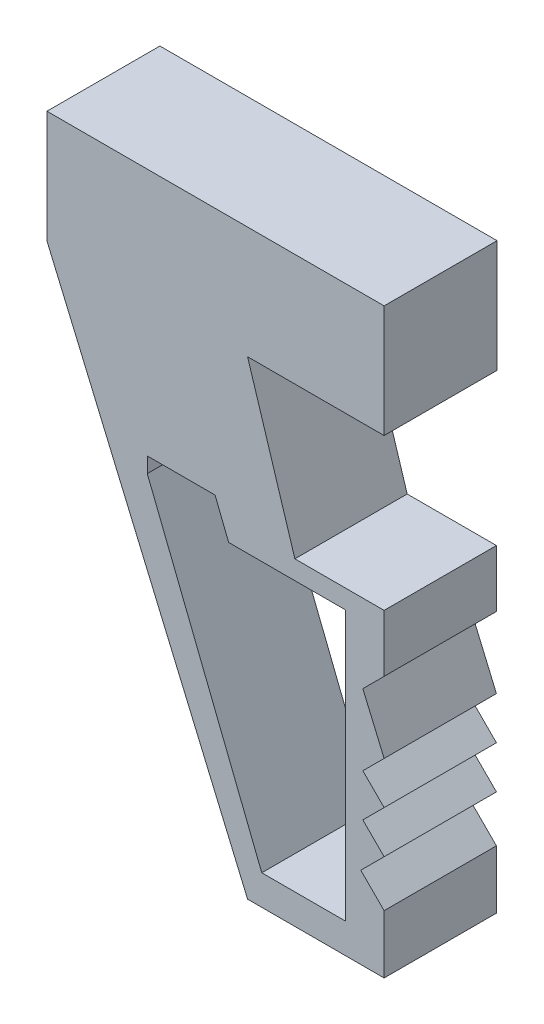
from build123d import *

# Parameters (mm, degrees)
SKETCH6_W           = 3002.111234572
SKETCH6_H           = 502.780765014
BOSS_EXTRUDE4_DEPTH = 500
BOSS_EXTRUDE5_DEPTH = 500
SKETCH8_W           = 2223.446103774
SKETCH8_H           = 2751.374812528
CUT_EXTRUDE1_DEPTH  = 1463


with BuildPart() as part:
    # Sketch6 → Boss-Extrude4 (new body)
    with BuildSketch(Plane(origin=(0, 0, 0), x_dir=(1, 0, 0), z_dir=(0, 1, 0))):
        Rectangle(SKETCH6_W, SKETCH6_H)
    extrude(amount=-BOSS_EXTRUDE4_DEPTH)

    # Sketch7 → Boss-Extrude5 (add)
    with BuildSketch(Plane.XY.offset(251.390382507)):
        Polygon((-1501.055617286, -500), (-607.842059568, -2591.411167057), (0, -2591.411167057), (0, -2331.810005358), (-103.950328884, -2227.859676474), (0, -2123.90934759), (-94.729662068, -2029.179685522), (0, -1934.450023454), (-94.729662068, -1839.720361386), (0, -1744.990699318), (-94.729662068, -1523.186326345), (0, -1428.456664277), (0, -1173.974742038), (-397.331699416, -1173.974742038), (-607.842059568, -500), align=None)
        Polygon((-1054.448838427, -1173.974742038), (-544.688951522, -2458.087938961), (-172.787315255, -2458.087938961), (-172.787315255, -1258.178886099), (-692.046203628, -1258.178886099), (-752.591786237, -1105.661232906), (-1054.448838427, -1105.661232906), align=None, mode=Mode.SUBTRACT)
    extrude(amount=-BOSS_EXTRUDE5_DEPTH)

    # Sketch8 → Cut-Extrude1 (cut)
    with BuildSketch(Plane.XY.offset(251.390382507)):
        with Locations((1111.723051887, -1375.687406264)):
            Rectangle(SKETCH8_W, SKETCH8_H)
    extrude(amount=-CUT_EXTRUDE1_DEPTH, mode=Mode.SUBTRACT)


solid = part.part
